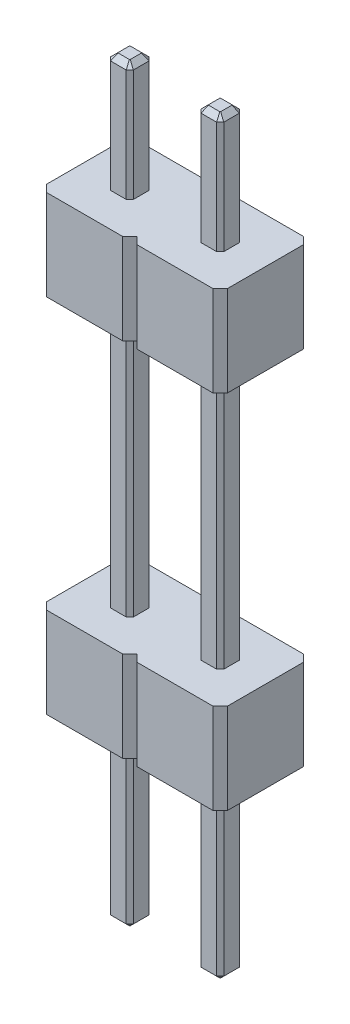
from build123d import *

# Parameters (mm, degrees)
EXTRUDE_1_DEPTH   = 5.08
EXTRUDE_1_2_DEPTH = 5.08
EXTRUDE_2_DEPTH   = 16
EXTRUDE_3_DEPTH   = 2.54
EXTRUDE_START     = 12.7
EXTRUDE_4_DEPTH   = 2.54
CHAMFER_1_SIZE    = 0.15


with BuildPart() as part:
    # Эскиз1 → Бобышка-Вытянуть1 (new body)
    with BuildSketch(Plane(origin=(0, 0, 0), x_dir=(1, 0, 0), z_dir=(0, 1, 0))):
        Polygon((-1.49, 0.32), (-1.59, 0.22), (-1.59, -0.22), (-1.49, -0.32), (-1.05, -0.32), (-0.95, -0.22), (-0.95, 0.22), (-1.05, 0.32), align=None)
    extrude(amount=-EXTRUDE_1_DEPTH)



with BuildPart() as body_2:
    # Эскиз1 → Extrude 1 2 (new body)
    with BuildSketch(Plane(origin=(0, 0, 0), x_dir=(1, 0, 0), z_dir=(0, 1, 0))):
        Polygon((1.05, 0.32), (0.95, 0.22), (0.95, -0.22), (1.05, -0.32), (1.49, -0.32), (1.59, -0.22), (1.59, 0.22), (1.49, 0.32), align=None)
    extrude(amount=-EXTRUDE_1_2_DEPTH)


with BuildPart() as part_1:
    add(part.part)

    add(body_2.part)  # Бобышка-Вытянуть2 merges body 2
    # Эскиз1<3> → Бобышка-Вытянуть2 (add)
    with BuildSketch(Plane(origin=(0, 0, 0), x_dir=(1, 0, 0), z_dir=(0, 1, 0))):
        Polygon((-1.49, 0.32), (-1.59, 0.22), (-1.59, -0.22), (-1.49, -0.32), (-1.05, -0.32), (-0.95, -0.22), (-0.95, 0.22), (-1.05, 0.32), align=None)
        Polygon((1.05, 0.32), (0.95, 0.22), (0.95, -0.22), (1.05, -0.32), (1.49, -0.32), (1.59, -0.22), (1.59, 0.22), (1.49, 0.32), align=None)
    extrude(amount=EXTRUDE_2_DEPTH)

    # Эскиз1<4> → Бобышка-Вытянуть3 (add)
    with BuildSketch(Plane(origin=(0, 0, 0), x_dir=(1, 0, 0), z_dir=(0, 1, 0))):
        Polygon((-0.2, 1.27), (-2.34, 1.27), (-2.54, 1.07), (-2.54, -1.07), (-2.34, -1.27), (-0.2, -1.27), (0, -1.07), (0.2, -1.27), (2.34, -1.27), (2.54, -1.07), (2.54, 1.07), (2.34, 1.27), (0.2, 1.27), (0, 1.07), align=None)
        Polygon((-1.59, -0.22), (-1.59, 0.22), (-1.49, 0.32), (-1.05, 0.32), (-0.95, 0.22), (-0.95, -0.22), (-1.05, -0.32), (-1.49, -0.32), align=None, mode=Mode.SUBTRACT)
        Polygon((0.95, 0.22), (1.05, 0.32), (1.49, 0.32), (1.59, 0.22), (1.59, -0.22), (1.49, -0.32), (1.05, -0.32), (0.95, -0.22), align=None, mode=Mode.SUBTRACT)
    extrude(amount=EXTRUDE_3_DEPTH)

    # Эскиз1<5> → Бобышка-Вытянуть4 (add)
    with BuildSketch(Plane(origin=(0, 0, 0), x_dir=(1, 0, 0), z_dir=(0, 1, 0)).offset(EXTRUDE_START)):
        Polygon((-0.2, 1.27), (-2.34, 1.27), (-2.54, 1.07), (-2.54, -1.07), (-2.34, -1.27), (-0.2, -1.27), (0, -1.07), (0.2, -1.27), (2.34, -1.27), (2.54, -1.07), (2.54, 1.07), (2.34, 1.27), (0.2, 1.27), (0, 1.07), align=None)
        Polygon((-1.59, -0.22), (-1.59, 0.22), (-1.49, 0.32), (-1.05, 0.32), (-0.95, 0.22), (-0.95, -0.22), (-1.05, -0.32), (-1.49, -0.32), align=None, mode=Mode.SUBTRACT)
        Polygon((0.95, 0.22), (1.05, 0.32), (1.49, 0.32), (1.59, 0.22), (1.59, -0.22), (1.49, -0.32), (1.05, -0.32), (0.95, -0.22), align=None, mode=Mode.SUBTRACT)
    extrude(amount=-EXTRUDE_4_DEPTH)

    # Фаска1
    chamfer_1_edges = [part_1.edges().sort_by_distance(p)[0] for p in [
        (-1.54, -5.08, 0.27),
        (-1.27, -5.08, 0.32),
        (-1, -5.08, 0.27),
        (-0.95, -5.08, 0),
        (-1, -5.08, -0.27),
        (-1.27, -5.08, -0.32),
        (-1.54, -5.08, -0.27),
        (-1.59, -5.08, 0),
        (1, -5.08, 0.27),
        (1.27, -5.08, 0.32),
        (1.54, -5.08, 0.27),
        (1.59, -5.08, 0),
        (1.54, -5.08, -0.27),
        (1.27, -5.08, -0.32),
        (1, -5.08, -0.27),
        (0.95, -5.08, 0),
        (1, 16, -0.27),
        (1.27, 16, -0.32),
        (1.54, 16, -0.27),
        (1.59, 16, 0),
        (1.54, 16, 0.27),
        (1.27, 16, 0.32),
        (1, 16, 0.27),
        (0.95, 16, 0),
        (-1.54, 16, -0.27),
        (-1.27, 16, -0.32),
        (-1, 16, -0.27),
        (-0.95, 16, 0),
        (-1, 16, 0.27),
        (-1.27, 16, 0.32),
        (-1.54, 16, 0.27),
        (-1.59, 16, 0),
    ]]
    chamfer(chamfer_1_edges, length=CHAMFER_1_SIZE)


solid = part_1.part
